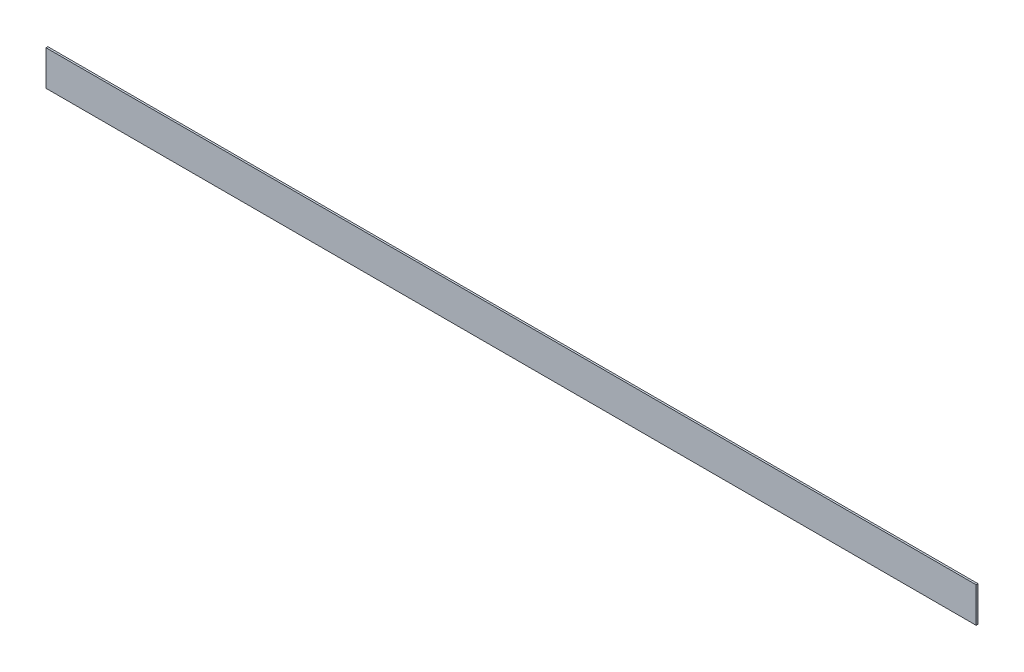
from build123d import *

# Parameters (mm, degrees)
SKETCH1_W           = 12700
SKETCH1_H           = 480
BOSS_EXTRUDE1_DEPTH = 25.4


with BuildPart() as part:
    # Sketch1 → Boss-Extrude1 (new body)
    with BuildSketch(Plane.XY):
        with Locations((6350, -240)):
            Rectangle(SKETCH1_W, SKETCH1_H)
    extrude(amount=BOSS_EXTRUDE1_DEPTH)


solid = part.part
